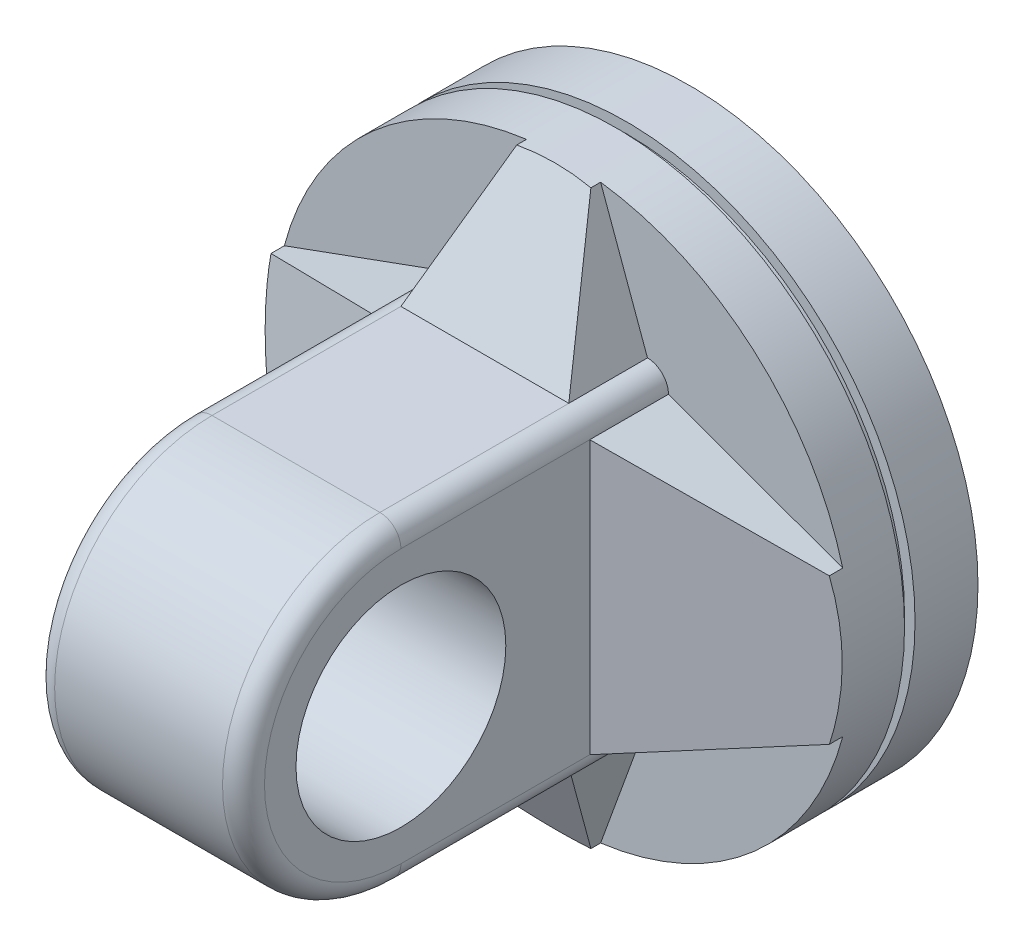
from build123d import *

# Parameters (mm, degrees)
SKETCH1_R           = 275
BOSS_EXTRUDE1_DEPTH = 70
SKETCH2_R           = 275
SKETCH2_R_2         = 265
CUT_EXTRUDE1_DEPTH  = 10
SKETCH3_R           = 275
BOSS_EXTRUDE2_DEPTH = 50
SKETCH4_R           = 150
SKETCH4_R_2         = 100
BOSS_EXTRUDE3_DEPTH = 100
BOSS_EXTRUDE4_DEPTH = 100
FILLET3_R           = 20
BOSS_EXTRUDE5_DEPTH = 75
CUT_EXTRUDE4_DEPTH  = 150
CUT_EXTRUDE5_DEPTH  = 87.5


with BuildPart() as part:
    # Sketch1 → Boss-Extrude1 (new body)
    with BuildSketch(Plane.XY):
        Circle(SKETCH1_R)
    extrude(amount=BOSS_EXTRUDE1_DEPTH)

    # Sketch2 → Cut-Extrude1 (cut)
    with BuildSketch(Plane.XY.offset(70)):
        Circle(SKETCH2_R)
        Circle(SKETCH2_R_2, mode=Mode.SUBTRACT)
    extrude(amount=-CUT_EXTRUDE1_DEPTH, mode=Mode.SUBTRACT)

    # Sketch3 → Boss-Extrude2 (add)
    with BuildSketch(Plane.XY.offset(70)):
        Circle(SKETCH3_R)
    extrude(amount=BOSS_EXTRUDE2_DEPTH)



with BuildPart() as body_2:
    # Sketch4 → Boss-Extrude3 (new body, symmetric)
    with BuildSketch(Plane(origin=(0, 0, 0), x_dir=(0, 0, -1), z_dir=(1, 0, 0))):
        with Locations((-375, 0)):
            Circle(SKETCH4_R)
        with Locations((-375, 0)):
            Circle(SKETCH4_R_2, mode=Mode.SUBTRACT)
    extrude(amount=BOSS_EXTRUDE3_DEPTH, both=True)


with BuildPart() as part_1:
    add(part.part)

    add(body_2.part)  # Boss-Extrude4 merges body 2
    # Sketch6 → Boss-Extrude4 (add, symmetric)
    with BuildSketch(Plane(origin=(0, 0, 0), x_dir=(0, 0, -1), z_dir=(1, 0, 0))):
        with BuildLine():
            Line((-375, 150), (-120, 150))
            Line((-120, 150), (-120, -150))
            Line((-120, -150), (-375, -150))
            ThreePointArc((-375, -150), (-225, 0), (-375, 150))
        make_face()
    extrude(amount=BOSS_EXTRUDE4_DEPTH, both=True)

    # Fillet3
    fillet3_edges = [part_1.edges().sort_by_distance(p)[0] for p in [
        (-100, -150, 247.5),
        (-100, 150, 247.5),
        (100, -150, 247.5),
        (100, 150, 247.5),
        (-100, 0, 525),
        (100, 0, 525),
    ]]
    fillet(fillet3_edges, radius=FILLET3_R)

    # Sketch7 → Boss-Extrude5 (add)
    with BuildSketch(Plane.XY.offset(120)):
        with BuildLine():
            ThreePointArc((-266.057108103, 69.560155462), (-275, 0), (-266.057108103, -69.560155462))
            Line((-266.057108103, -69.560155462), (-100, -130))
            Line((-100, -130), (-100, 130))
            Line((-100, 130), (-266.057108103, 69.560155462))
        make_face()
        with BuildLine():
            Line((100, -130), (266.057108103, -69.560155462))
            ThreePointArc((266.057108103, -69.560155462), (272.755114277, -35.066331942), (275, 0))
            ThreePointArc((275, 0), (272.755114277, 35.066331942), (266.057108103, 69.560155462))
            Line((266.057108103, 69.560155462), (100, 130))
            Line((100, 130), (100, -130))
        make_face()
        with BuildLine():
            ThreePointArc((35.333334581, 272.72065464), (0, 275), (-35.333334581, 272.72065464))
            Line((-35.333334581, 272.72065464), (-80, 150))
            Line((-80, 150), (80, 150))
            Line((80, 150), (35.333334581, 272.72065464))
        make_face()
        with BuildLine():
            Line((80, -150), (-80, -150))
            Line((-80, -150), (-35.333334581, -272.72065464))
            ThreePointArc((-35.333334581, -272.72065464), (0, -275), (35.333334581, -272.72065464))
            Line((35.333334581, -272.72065464), (80, -150))
        make_face()
    extrude(amount=BOSS_EXTRUDE5_DEPTH)

    # Sketch8 → Cut-Extrude4 (cut, symmetric)
    with BuildSketch(Plane(origin=(0, 0, 0), x_dir=(1, 0, 0), z_dir=(0, 1, 0))):
        Polygon((-300, -120), (-100, -195), (-300, -195), align=None)
        Polygon((300, -120), (100, -195), (300, -195), align=None)
    extrude(amount=CUT_EXTRUDE4_DEPTH, both=True, mode=Mode.SUBTRACT)

    # Sketch9 → Cut-Extrude5 (cut, symmetric)
    with BuildSketch(Plane(origin=(0, 0, 0), x_dir=(0, 0, -1), z_dir=(1, 0, 0))):
        Polygon((-195, 150), (-195, 290), (-120, 290), align=None)
        Polygon((-120, -290), (-195, -150), (-195, -290), align=None)
    extrude(amount=CUT_EXTRUDE5_DEPTH, both=True, mode=Mode.SUBTRACT)


solid = part_1.part
